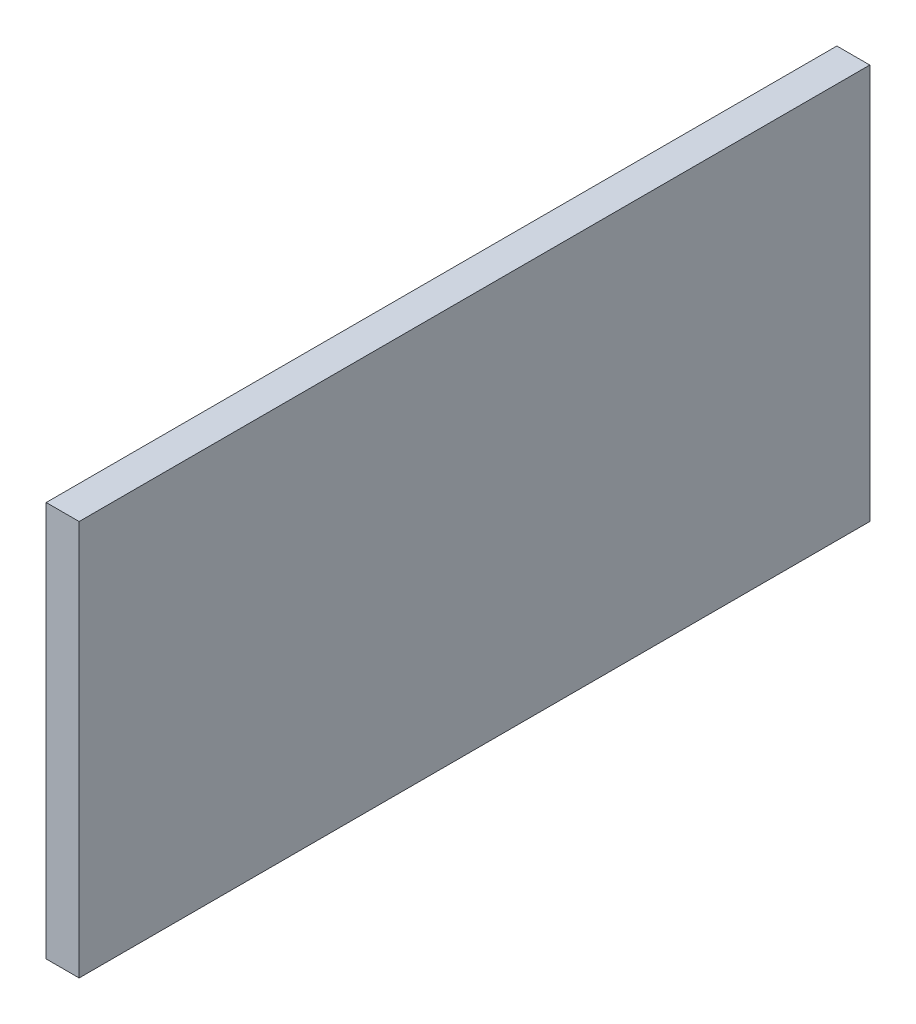
from build123d import *

# Parameters (mm, degrees)
SKETCH1_W           = 304.8
SKETCH1_H           = 152.4
BOSS_EXTRUDE1_DEPTH = 12.7


with BuildPart() as part:
    # Sketch1 → Boss-Extrude1 (new body)
    with BuildSketch(Plane(origin=(0, 0, 0), x_dir=(0, 0, -1), z_dir=(1, 0, 0))):
        Rectangle(SKETCH1_W, SKETCH1_H)
    extrude(amount=BOSS_EXTRUDE1_DEPTH)


solid = part.part
